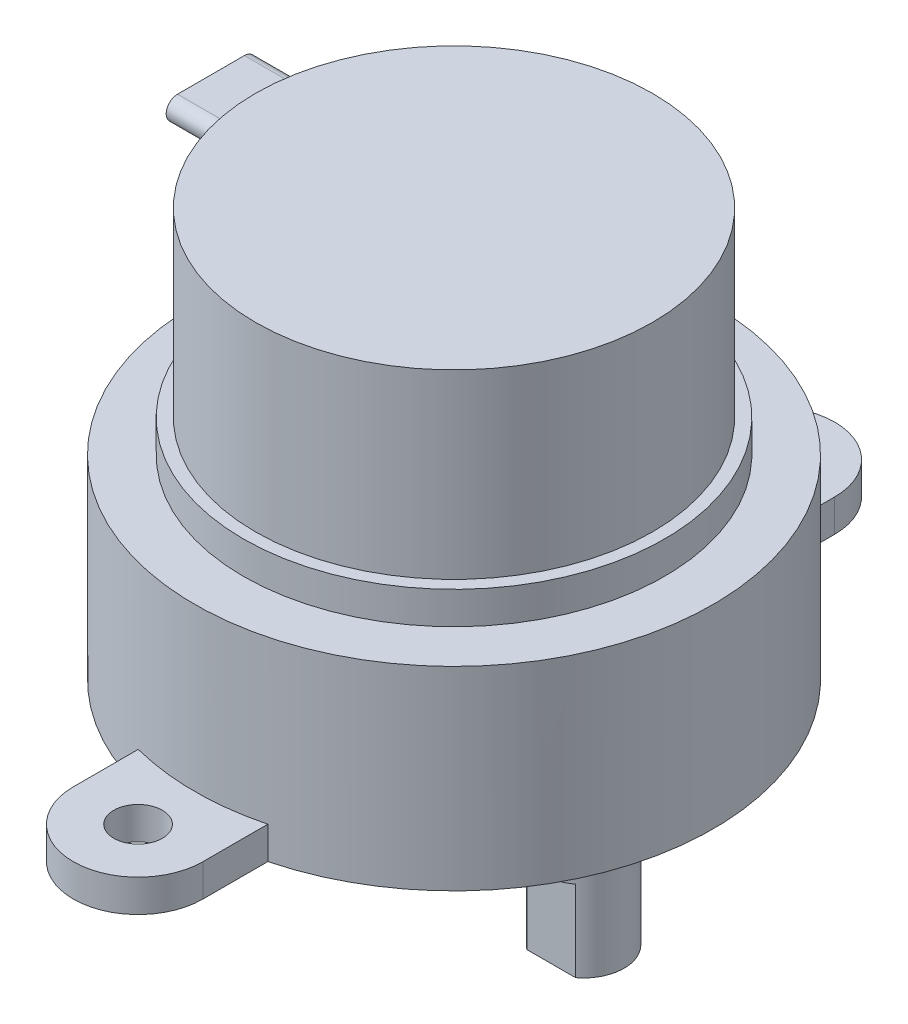
from build123d import *

# Parameters (mm, degrees)
M3_TAPPED_HOLE1_D     = 2.5
M3_TAPPED_HOLE1_DEPTH = 7.5
M3_TAPPED_HOLE1_TIP   = 0.751075774
SKETCH5_W             = 11.224279957
SKETCH5_H             = 5.216918853
SKETCH5_W_2           = 10.939720747
SKETCH5_H_2           = 5.185301163
CUT_EXTRUDE1_DEPTH    = 5
SKETCH6_R             = 1.5
BOSS_EXTRUDE1_DEPTH   = 2
BOSS_EXTRUDE2_DEPTH   = 15


with BuildPart() as part:
    # Sketch1 → Revolve1 (revolve)
    with BuildSketch(Plane.XY):
        Polygon((0, 0), (-16, 0), (-16, 12), (-13, 12), (-13, 14), (-12.25, 14), (-12.25, 25.2), (0, 25.2), align=None)
    revolve(axis=Axis((0, 0, 0), (0, 1, 0)))

    # Sketch2 → Revolve2 (revolve)
    with BuildSketch(Plane.XY):
        Polygon((4, -2.7), (4, -1.25), (3.5, -1.25), (3.5, 0), (8, 0), (8, -10.2), (5.5, -10.2), (5.5, -2.7), align=None)
    revolve(axis=Axis((8, 0, 0), (0, -1, 0)))

    # M3 Tapped Hole1
    with Locations(Plane(origin=(0, -10.2, 0), x_dir=(-1, 0, 0), z_dir=(0, -1, 0))):
        with Locations((-8, 0)):
            Hole(M3_TAPPED_HOLE1_D / 2, depth=M3_TAPPED_HOLE1_DEPTH)
            with Locations((0, 0, -(M3_TAPPED_HOLE1_DEPTH + M3_TAPPED_HOLE1_TIP / 2))):  # 118° drill point
                Cone(0, M3_TAPPED_HOLE1_D / 2, M3_TAPPED_HOLE1_TIP, mode=Mode.SUBTRACT)

    # Sketch5 → Cut-Extrude1 (cut)
    with BuildSketch(Plane.XZ.offset(10.2)):
        with Locations((7.653051139, 4.608459426)):
            Rectangle(SKETCH5_W, SKETCH5_H)
        with Locations((7.795330744, -4.592650582)):
            Rectangle(SKETCH5_W_2, SKETCH5_H_2)
    extrude(amount=-CUT_EXTRUDE1_DEPTH, mode=Mode.SUBTRACT)

    # Sketch6 → Boss-Extrude1 (add)
    with BuildSketch(Plane.XZ):
        with BuildLine():
            Line((-4, -19.5), (-4, 19.5))
            ThreePointArc((-4, 19.5), (0, 23.5), (4, 19.5))
            Line((4, 19.5), (4, -19.5))
            ThreePointArc((4, -19.5), (0, -23.5), (-4, -19.5))
        make_face()
        with Locations((0, -19.5)):
            Circle(SKETCH6_R, mode=Mode.SUBTRACT)
        with Locations((0, 19.5)):
            Circle(SKETCH6_R, mode=Mode.SUBTRACT)
    extrude(amount=-BOSS_EXTRUDE1_DEPTH)

    # Sketch7 → Boss-Extrude2 (add)
    with BuildSketch(Plane(origin=(0, 0, 0), x_dir=(0, 0, -1), z_dir=(1, 0, 0))):
        with BuildLine():
            Line((-2.065333305, 24.81029355), (2.065333305, 24.81029355))
            ThreePointArc((2.065333305, 24.81029355), (2.76544629, 24.110180565), (2.065333305, 23.410067581))
            Line((2.065333305, 23.410067581), (-2.065333305, 23.410067581))
            ThreePointArc((-2.065333305, 23.410067581), (-2.76544629, 24.110180565), (-2.065333305, 24.81029355))
        make_face()
    extrude(amount=-BOSS_EXTRUDE2_DEPTH)


solid = part.part
